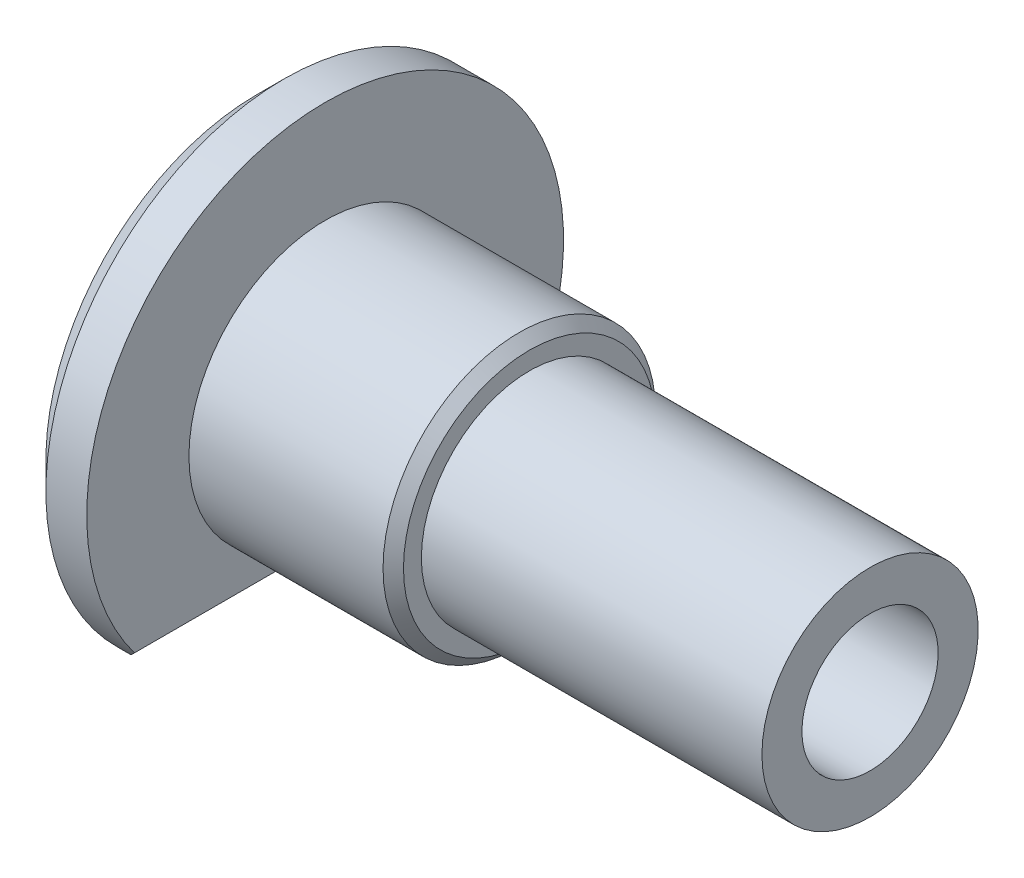
from build123d import *

# Parameters (mm, degrees)
CUT_EXTRUDE_2_DEPTH = 19
CHAMFER_1_SIZE      = 0.8


with BuildPart() as part:
    # Эскиз1 → Повернуть1 (revolve)
    with BuildSketch(Plane(origin=(0, 0, 0), x_dir=(1, 0, 0), z_dir=(0, 1, 0))):
        Polygon((0, 2), (18, 2), (18, 3.175), (8, 3.175), (8, 3.7), (7.7, 4), (2, 4), (2, 7), (0, 7), align=None)
    revolve(axis=Axis((0, 0, 0), (1, 0, 0)))

    # Эскиз2 → Вырез-Вытянуть2 (cut, through all)
    with BuildSketch(Plane.ZY):
        with BuildLine():
            Line((4.898979486, -5), (-4.898979486, -5))
            ThreePointArc((-4.898979486, -5), (0, -7), (4.898979486, -5))
        make_face()
    extrude(amount=-CUT_EXTRUDE_2_DEPTH, mode=Mode.SUBTRACT)

    # Фаска1
    chamfer_1_edges = [part.edges().sort_by_distance(p)[0] for p in [
        (0, 7, 0),
        (2, -5, 0),
    ]]
    chamfer(chamfer_1_edges, length=CHAMFER_1_SIZE)


solid = part.part
